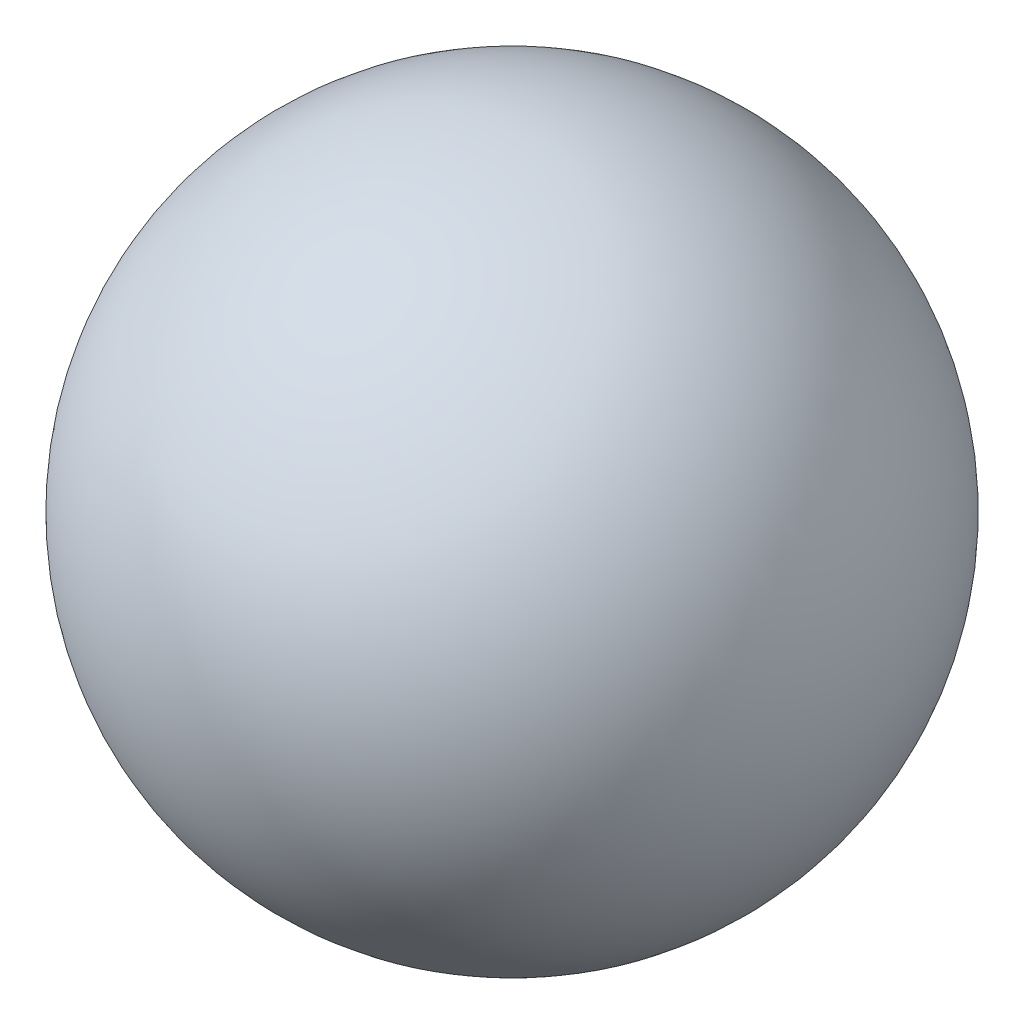
from build123d import *


with BuildPart() as part:
    # Sketch1 → Revolve1 (revolve)
    with BuildSketch(Plane.XY):
        with BuildLine():
            Line((0, 0.889), (0, -0.889))
            ThreePointArc((0, -0.889), (-0.889, 0), (0, 0.889))
        make_face()
    revolve(axis=Axis((0, 0.889, 0), (0, -1, 0)))


solid = part.part
